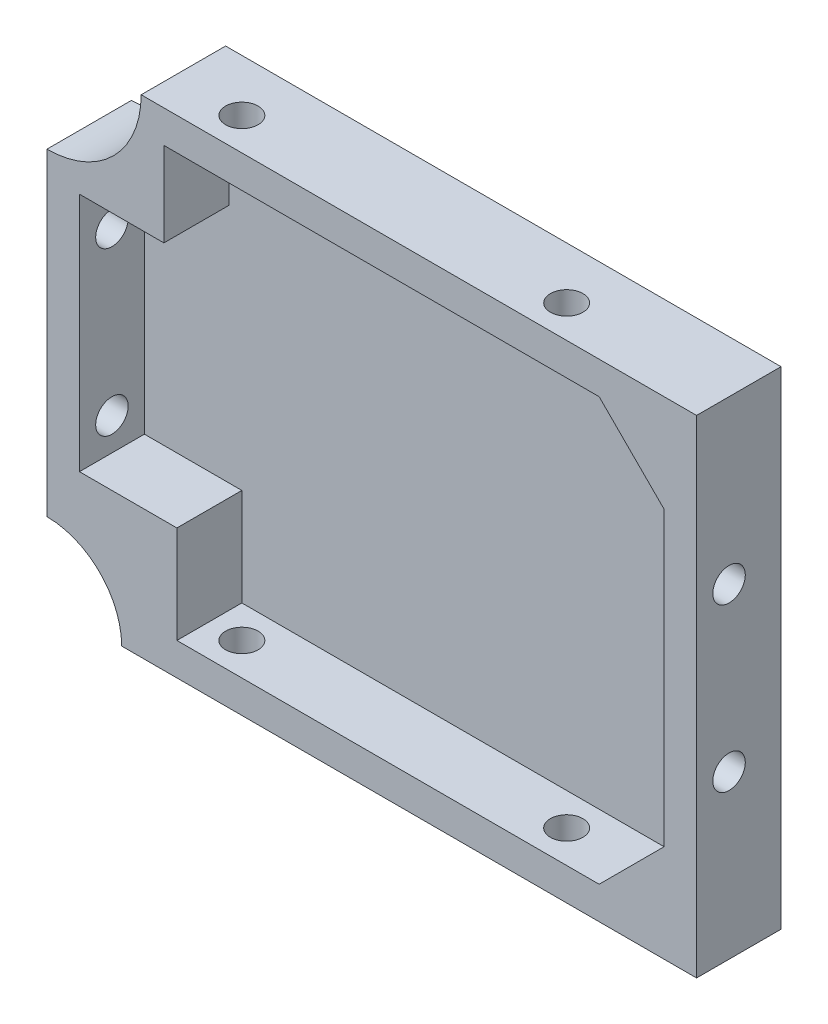
from build123d import *

# Parameters (mm, degrees)
BOSS_EXTRU_1_DEPTH        = 13
COQUE1_T                  = -5
COQUE1_THICKNESS_2_FACE_W = 90
COQUE1_THICKNESS_2_FACE_H = 65
COQUE1_THICKNESS_2_DEPTH  = 2
ENL_V_MAT_EXTRU_1_REACH   = 110.96
ESQUISSE2_R               = 2.5
ENL_V_MAT_EXTRU_2_REACH   = 95.396
ESQUISSE3_R               = 2.5
ESQUISSE4_W               = 18
ESQUISSE4_H               = 18
ESQUISSE4_W_2             = 15
ESQUISSE4_H_2             = 15
BOSS_EXTRU_2_DEPTH        = 10
ESQUISSE6_R               = 11.5
ESQUISSE6_R_2             = 14.5
ENL_V_MAT_EXTRU_4_DEPTH   = 13


with BuildPart() as part:
    # Esquisse1 → Boss.-Extru.1 (new body)
    with BuildSketch(Plane.XY):
        Polygon((44.118436308, 33.728448276), (54.118436308, 33.728448276), (54.118436308, 23.728448276), (54.118436308, -41.271551724), (-45.881563692, -41.271551724), (-45.881563692, 33.728448276), align=None)
    extrude(amount=BOSS_EXTRU_1_DEPTH)

    # Coque1
    coque1_openings = [part.faces().sort_by_distance(p)[0] for p in [
        (4.118436308, -3.771551724, 13),
    ]]
    offset(amount=COQUE1_T, openings=coque1_openings, kind=Kind.INTERSECTION)

    # Coque1 thickness 2 face (on inner face of the shell) → Coque1 thickness 2 (cut)
    with BuildSketch(Plane(origin=(4.118436308, -3.771551724, 5), x_dir=(-1, 0, 0), z_dir=(0, 0, -1))):
        Rectangle(COQUE1_THICKNESS_2_FACE_W, COQUE1_THICKNESS_2_FACE_H)
    extrude(amount=COQUE1_THICKNESS_2_DEPTH, mode=Mode.SUBTRACT)

    # Enlèv. mat.-Extru.1: up to this face of the body (flat: up to its plane)
    enl_v_mat_extru_1_end = Plane(part.part.faces().sort_by_distance((54.118436308, -3.771551724, 6.5))[0])
    # Esquisse2 → Enlèv. mat.-Extru.1 (cut, up to the picked face)
    with BuildSketch(Plane.ZY.offset(45.881563692), mode=Mode.PRIVATE) as enl_v_mat_extru_1_sk1:
        with Locations(Location((8, -16.271551724, 0), (0, 0, 270))):
            Circle(ESQUISSE2_R)
    enl_v_mat_extru_1_tool1 = split(extrude(enl_v_mat_extru_1_sk1.sketch, amount=-ENL_V_MAT_EXTRU_1_REACH, mode=Mode.PRIVATE), bisect_by=enl_v_mat_extru_1_end, keep=Keep.BOTH, mode=Mode.PRIVATE)
    # Esquisse2 → Enlèv. mat.-Extru.1 (cut, up to the picked face)
    with BuildSketch(Plane.ZY.offset(45.881563692), mode=Mode.PRIVATE) as enl_v_mat_extru_1_sk2:
        with Locations(Location((8, 8.728448276, 0), (0, 0, 270))):
            Circle(ESQUISSE2_R)
    enl_v_mat_extru_1_tool2 = split(extrude(enl_v_mat_extru_1_sk2.sketch, amount=-ENL_V_MAT_EXTRU_1_REACH, mode=Mode.PRIVATE), bisect_by=enl_v_mat_extru_1_end, keep=Keep.BOTH, mode=Mode.PRIVATE)
    add(enl_v_mat_extru_1_tool1.solids().sort_by(Axis((-45.881564, -16.271552, 8), (1, 0, 0)))[0], mode=Mode.SUBTRACT)
    add(enl_v_mat_extru_1_tool2.solids().sort_by(Axis((-45.881564, 8.728448, 8), (1, 0, 0)))[0], mode=Mode.SUBTRACT)

    # Enlèv. mat.-Extru.2: up to this face of the body (flat: up to its plane)
    enl_v_mat_extru_2_end = Plane(part.part.faces().sort_by_distance((4.118436308, 33.728448276, 6.5))[0])
    # Esquisse3 → Enlèv. mat.-Extru.2 (cut, up to the picked face)
    with BuildSketch(Plane.XZ.offset(41.271551724), mode=Mode.PRIVATE) as enl_v_mat_extru_2_sk1:
        with Locations(Location((-20.881563692, 8, 0), (0, 0, 270))):
            Circle(ESQUISSE3_R)
    enl_v_mat_extru_2_tool1 = split(extrude(enl_v_mat_extru_2_sk1.sketch, amount=-ENL_V_MAT_EXTRU_2_REACH, mode=Mode.PRIVATE), bisect_by=enl_v_mat_extru_2_end, keep=Keep.BOTH, mode=Mode.PRIVATE)
    # Esquisse3 → Enlèv. mat.-Extru.2 (cut, up to the picked face)
    with BuildSketch(Plane.XZ.offset(41.271551724), mode=Mode.PRIVATE) as enl_v_mat_extru_2_sk2:
        with Locations(Location((29.118436308, 8, 0), (0, 0, 270))):
            Circle(ESQUISSE3_R)
    enl_v_mat_extru_2_tool2 = split(extrude(enl_v_mat_extru_2_sk2.sketch, amount=-ENL_V_MAT_EXTRU_2_REACH, mode=Mode.PRIVATE), bisect_by=enl_v_mat_extru_2_end, keep=Keep.BOTH, mode=Mode.PRIVATE)
    add(enl_v_mat_extru_2_tool1.solids().sort_by(Axis((-20.881564, -41.271552, 8), (0, 1, 0)))[0], mode=Mode.SUBTRACT)
    add(enl_v_mat_extru_2_tool2.solids().sort_by(Axis((29.118436, -41.271552, 8), (0, 1, 0)))[0], mode=Mode.SUBTRACT)

    # Esquisse4 → Boss.-Extru.2 (add)
    with BuildSketch(Plane.XY.offset(3)):
        with Locations((-36.881563692, 24.728448276)):
            Rectangle(ESQUISSE4_W, ESQUISSE4_H)
        Polygon((49.118436308, 28.728448276), (49.118436308, 18.728448276), (39.118436308, 28.728448276), align=None)
        Polygon((49.118436308, -36.271551724), (49.118436308, -26.271551724), (39.118436308, -36.271551724), align=None)
        with Locations((-33.381563692, -28.771551724)):
            Rectangle(ESQUISSE4_W_2, ESQUISSE4_H_2)
    extrude(amount=BOSS_EXTRU_2_DEPTH)

    # Esquisse6 → Enlèv. mat.-Extru.4 (cut)
    with BuildSketch(Plane.XY.offset(13)):
        with Locations((-45.881563692, -41.271551724)):
            Circle(ESQUISSE6_R)
        with Locations((-45.881563692, 33.728448276)):
            Circle(ESQUISSE6_R_2)
    extrude(amount=-ENL_V_MAT_EXTRU_4_DEPTH, mode=Mode.SUBTRACT)


solid = part.part
